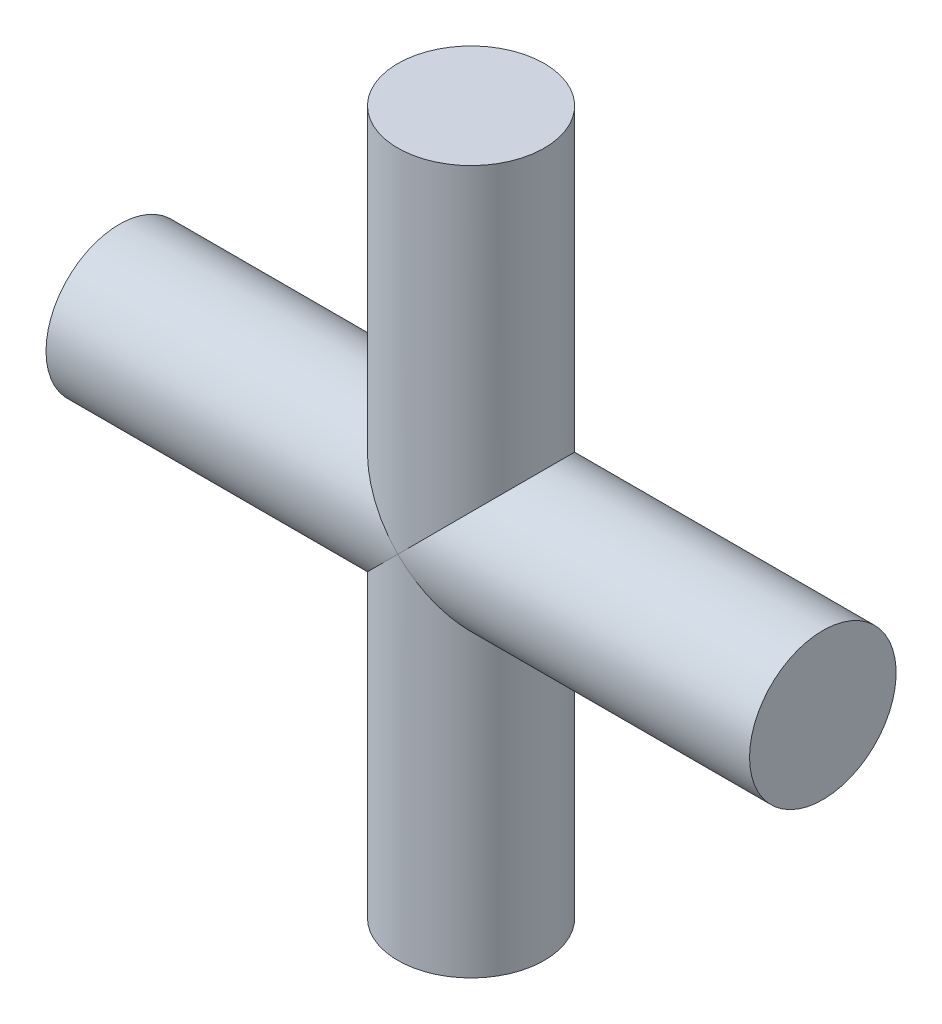
from build123d import *


with BuildPart() as part:
    # 草图4 → 旋转5 (revolve)
    with BuildSketch(Plane(origin=(0, 0, 0), x_dir=(1, 0, 0), z_dir=(0, 1, 0))):
        Polygon((0, 0), (1.2, 0), (1.2, -0.25), (-1.2, -0.25), (-1.2, 0), align=None)
    revolve(axis=Axis((-1.2, 0, 0), (1, 0, 0)))

    # 草图5 → 旋转6 (revolve)
    with BuildSketch(Plane.XY):
        Polygon((0, 0), (0, 1.2), (0.25, 1.2), (0.25, -1.2), (0, -1.2), align=None)
    revolve(axis=Axis((0, 0, 0), (0, 1, 0)))


solid = part.part
